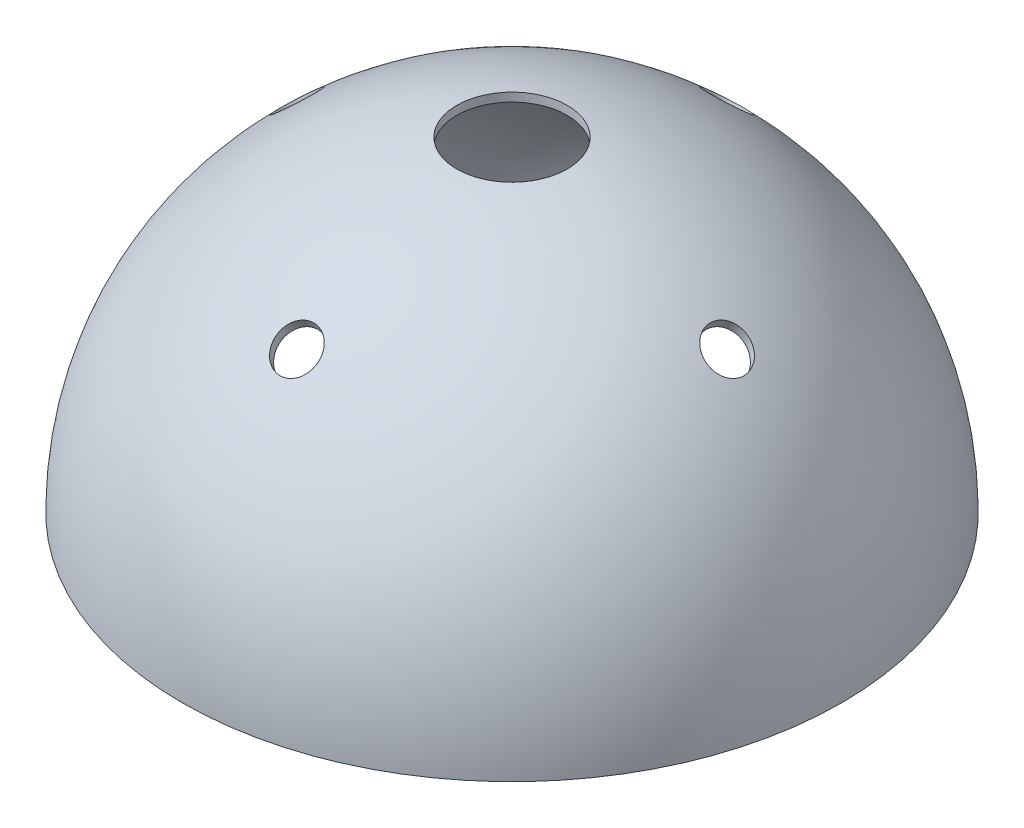
from build123d import *

# Parameters (mm, degrees)
SKETCH21_W                  = 2.484027853
SKETCH21_H                  = 35.042476462
CIRPATTERN4_COUNT           = 2
CIRPATTERN4_ANGLE           = 27
CIRPATTERN5_COPY_1_SKETCH_W = 2.484027853
CIRPATTERN5_COPY_1_SKETCH_H = 35.042476462
CIRPATTERN5_COPY_2_SKETCH_W = 2.484027853
CIRPATTERN5_COPY_2_SKETCH_H = 35.042476462
CIRPATTERN5_COPY_3_SKETCH_W = 2.484027853
CIRPATTERN5_COPY_3_SKETCH_H = 35.042476462
CIRPATTERN5_COPY_4_SKETCH_W = 2.484027853
CIRPATTERN5_COPY_4_SKETCH_H = 35.042476462
CIRPATTERN5_COPY_5_SKETCH_W = 2.484027853
CIRPATTERN5_COPY_5_SKETCH_H = 35.042476462
CIRPATTERN5_COPY_6_SKETCH_W = 2.484027853
CIRPATTERN5_COPY_6_SKETCH_H = 35.042476462
SKETCH16_W                  = 6.362872572
SKETCH16_H                  = 12.097313285


with BuildPart() as part:
    # Sketch6 → Revolve3 (revolve)
    with BuildSketch(Plane.XY):
        with BuildLine():
            Line((0, 37.973444165), (0, 0))
            Line((0, 0), (37.973444165, 0))
            ThreePointArc((37.973444165, 0), (26.851279874, 26.851279874), (0, 37.973444165))
        make_face()
    revolve(axis=Axis((0, 37.973444165, 0), (0, -1, 0)))

    # Sketch21 → Cut-Revolve16 (revolve, cut)
    with BuildSketch(Plane.XY):
        with Locations((1.242013927, 26.723238857)):
            Rectangle(SKETCH21_W, SKETCH21_H)
    cut_revolve16 = revolve(axis=Axis((0, 0, 0), (0, 1, 0)), mode=Mode.SUBTRACT)

    # CirPattern4: Cut-Revolve16 ×2 about axis
    cirpattern4_axis = Axis((0, -19.950289218, 0), (0, 0, 1))
    for i in range(1, CIRPATTERN4_COUNT):
        add(cut_revolve16.rotate(cirpattern4_axis, i * CIRPATTERN4_ANGLE / (CIRPATTERN4_COUNT - 1)), mode=Mode.SUBTRACT)

    # CirPattern5 copy 1 sketch → CirPattern5 copy 1 (revolve, cut)
    with BuildSketch(Plane(origin=(0, -2.174451365, -9.057241772), x_dir=(0, 0.45399049973954775, 0.8910065241883673), z_dir=(-1, 0, 0))):
        with Locations((1.242013927, 26.723238857)):
            Rectangle(CIRPATTERN5_COPY_1_SKETCH_W, CIRPATTERN5_COPY_1_SKETCH_H)
    revolve(axis=Axis((0, -2.174451365, -9.057241772), (0, 0.8910065241883673, -0.45399049973954775)), mode=Mode.SUBTRACT)

    # CirPattern5 copy 2 sketch → CirPattern5 copy 2 (revolve, cut)
    with BuildSketch(Plane(origin=(9.057241772, -2.174451365, 0), x_dir=(-0.8910065241883673, 0.45399049973954775, 0), z_dir=(0, 0, -1))):
        with Locations((1.242013927, 26.723238857)):
            Rectangle(CIRPATTERN5_COPY_2_SKETCH_W, CIRPATTERN5_COPY_2_SKETCH_H)
    revolve(axis=Axis((9.057241772, -2.174451365, 0), (0.45399049973954775, 0.8910065241883673, 0)), mode=Mode.SUBTRACT)

    # CirPattern5 copy 3 sketch → CirPattern5 copy 3 (revolve, cut)
    with BuildSketch(Plane(origin=(0, -2.174451365, 9.057241772), x_dir=(0, 0.45399049973954775, -0.8910065241883673), z_dir=(1, 0, 0))):
        with Locations((1.242013927, 26.723238857)):
            Rectangle(CIRPATTERN5_COPY_3_SKETCH_W, CIRPATTERN5_COPY_3_SKETCH_H)
    revolve(axis=Axis((0, -2.174451365, 9.057241772), (0, 0.8910065241883673, 0.45399049973954775)), mode=Mode.SUBTRACT)

    # CirPattern5 copy 4 sketch → CirPattern5 copy 4 (revolve, cut)
    with BuildSketch(Plane.ZY):
        with Locations((1.242013927, 26.723238857)):
            Rectangle(CIRPATTERN5_COPY_4_SKETCH_W, CIRPATTERN5_COPY_4_SKETCH_H)
    revolve(axis=Axis((0, 0, 0), (0, 1, 0)), mode=Mode.SUBTRACT)

    # CirPattern5 copy 5 sketch → CirPattern5 copy 5 (revolve, cut)
    with BuildSketch(Plane(origin=(0, 0, 0), x_dir=(-1, 0, 0), z_dir=(0, 0, -1))):
        with Locations((1.242013927, 26.723238857)):
            Rectangle(CIRPATTERN5_COPY_5_SKETCH_W, CIRPATTERN5_COPY_5_SKETCH_H)
    revolve(axis=Axis((0, 0, 0), (0, 1, 0)), mode=Mode.SUBTRACT)

    # CirPattern5 copy 6 sketch → CirPattern5 copy 6 (revolve, cut)
    with BuildSketch(Plane(origin=(0, 0, 0), x_dir=(0, 0, -1), z_dir=(1, 0, 0))):
        with Locations((1.242013927, 26.723238857)):
            Rectangle(CIRPATTERN5_COPY_6_SKETCH_W, CIRPATTERN5_COPY_6_SKETCH_H)
    revolve(axis=Axis((0, 0, 0), (0, 1, 0)), mode=Mode.SUBTRACT)

    # Sketch22 → Cut-Revolve17 (revolve, cut)
    with BuildSketch(Plane(origin=(0, 0, 0), x_dir=(0, 0, -1), z_dir=(1, 0, 0))):
        with BuildLine():
            Line((0, 0), (0, 36.987197209))
            ThreePointArc((0, 36.987197209), (-26.167571908, 26.159561897), (-37.014545099, 0))
            Line((-37.014545099, 0), (0, 0))
        make_face()
    revolve(axis=Axis((0, 0, 0), (0, 1, 0)), mode=Mode.SUBTRACT)

    # Sketch16 → Cut-Revolve18 (revolve, cut)
    with BuildSketch(Plane.XY):
        with Locations((-3.181436286, 39.933029211)):
            Rectangle(SKETCH16_W, SKETCH16_H)
    revolve(axis=Axis((0, 45.981685853, 0), (0, -1, 0)), mode=Mode.SUBTRACT)


solid = part.part
